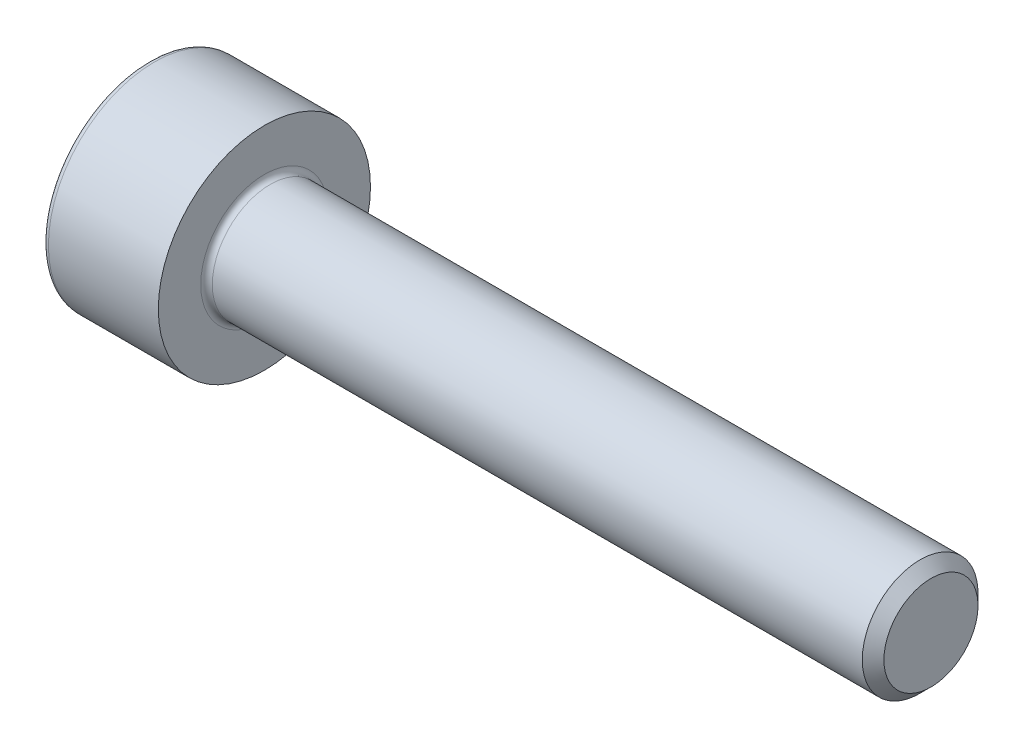
from build123d import *

# Parameters (mm, degrees)
FILLET2_R          = 0.15
CUT_EXTRUDE1_DEPTH = 1


with BuildPart() as part:
    # Sketch1 → Revolve2 (revolve)
    with BuildSketch(Plane(origin=(0, 0, 0), x_dir=(1, 0, 0), z_dir=(0, 1, 0))):
        Polygon((-11.44921875, 2.298828125), (-11.44921875, -0.451171875), (8.83128125, -0.451171875), (8.83128125, 0.768328125), (8.55078125, 1.048828125), (-8.44921875, 1.048828125), (-8.44921875, 2.298828125), align=None)
    revolve(axis=Axis((-15.512494932, 0, 0.451171875), (1, 0, 0)))

    # Fillet2
    fillet2_edges = [part.edges().sort_by_distance(p)[0] for p in [
        (-11.44921875, 0, 3.201171875),
        (-8.44921875, 0, 1.951171875),
    ]]
    fillet(fillet2_edges, radius=FILLET2_R)

    # Sketch3 → Cut-Extrude1 (cut)
    with BuildSketch(Plane.ZY.offset(11.44921875)):
        Polygon((1.190118859, -1.280035428), (1.929188565, -7.0854e-05), (1.190241581, 1.279964574), (-0.287775109, 1.280035428), (-1.026844815, 7.0854e-05), (-0.287897831, -1.279964574), align=None)
    extrude(amount=-CUT_EXTRUDE1_DEPTH, mode=Mode.SUBTRACT)


solid = part.part
